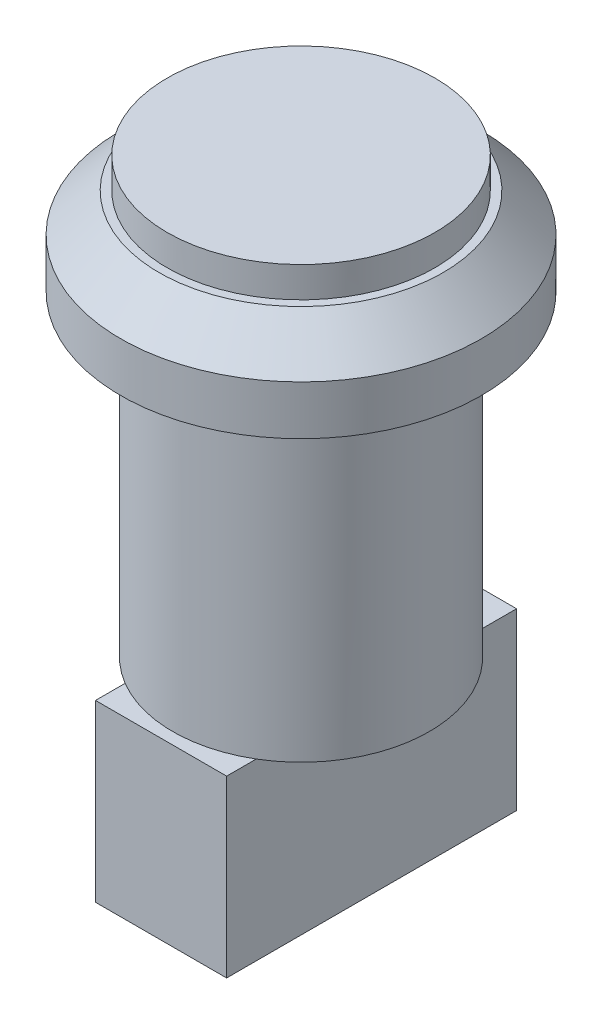
from build123d import *

# Parameters (mm, degrees)
SKETCH1_R           = 12.25
BOSS_EXTRUDE1_DEPTH = 2.8
SKETCH2_R           = 16.5
BOSS_EXTRUDE2_DEPTH = 8
CHAMFER1_SIZE       = 3.5
SKETCH3_R           = 11.75
BOSS_EXTRUDE3_DEPTH = 29
SKETCH4_W           = 12
SKETCH4_H           = 26.533921206
BOSS_EXTRUDE4_DEPTH = 16


with BuildPart() as part:
    # Sketch1 → Boss-Extrude1 (new body)
    with BuildSketch(Plane(origin=(0, 0, 0), x_dir=(1, 0, 0), z_dir=(0, 1, 0))):
        Circle(SKETCH1_R)
    extrude(amount=BOSS_EXTRUDE1_DEPTH)

    # Sketch2 → Boss-Extrude2 (add)
    with BuildSketch(Plane.XZ):
        Circle(SKETCH2_R)
    extrude(amount=BOSS_EXTRUDE2_DEPTH)

    # Chamfer1
    chamfer1_edges = [part.edges().sort_by_distance(p)[0] for p in [
        (-16.5, 0, 0),
    ]]
    chamfer(chamfer1_edges, length=CHAMFER1_SIZE)

    # Sketch3 → Boss-Extrude3 (add)
    with BuildSketch(Plane.XZ.offset(8)):
        Circle(SKETCH3_R)
    extrude(amount=BOSS_EXTRUDE3_DEPTH)

    # Sketch4 → Boss-Extrude4 (add)
    with BuildSketch(Plane.XZ.offset(37)):
        with Locations((0, -0.455127293)):
            Rectangle(SKETCH4_W, SKETCH4_H)
    extrude(amount=BOSS_EXTRUDE4_DEPTH)


solid = part.part
